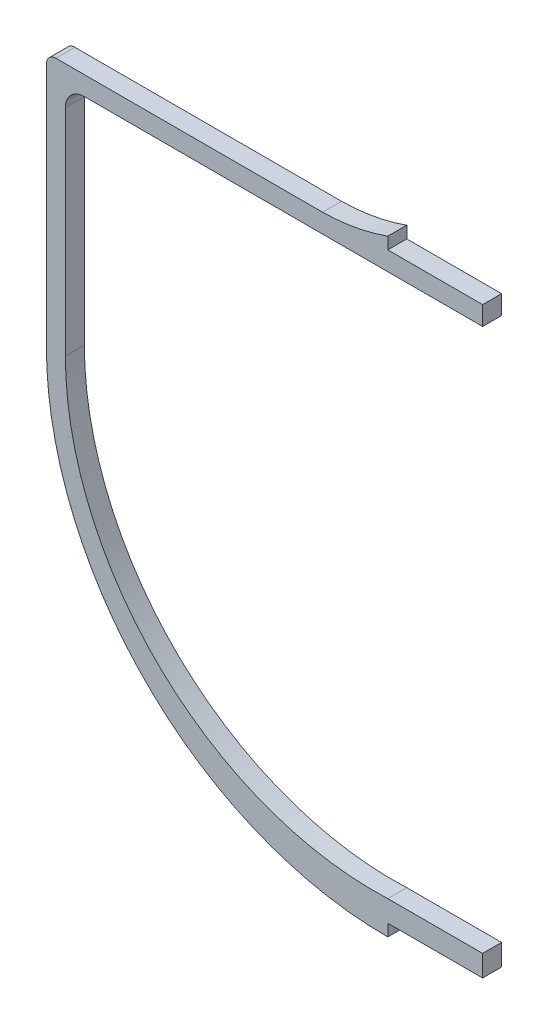
from build123d import *

# Parameters (mm, degrees)
BOSS_EXTRUDE1_DEPTH = 4
FILLET1_R           = 4
FILLET2_R           = 2


with BuildPart() as part:
    # Sketch1 → Boss-Extrude1 (new body)
    with BuildSketch(Plane.XY):
        with BuildLine():
            Line((0, 0), (0, 2.5))
            Line((0, 2.5), (20, 2.5))
            Line((20, 2.5), (20, 7))
            Line((20, 7), (0, 7))
            ThreePointArc((0, 7), (-47.899542657, 25.027060394), (-68, 72.09416895))
            Line((-68, 72.09416895), (-68, 121.5))
            Line((-68, 121.5), (20, 121.5))
            Line((20, 121.5), (20, 125.5))
            Line((20, 125.5), (0, 125.5))
            Line((0, 125.5), (0, 128))
            ThreePointArc((0, 128), (-6.772700236, 126.180912146), (-13.752306798, 125.5))
            Line((-13.752306798, 125.5), (-68, 125.5))
            Line((-68, 125.5), (-72, 125.5))
            Line((-72, 125.5), (-72, 72.09416895))
            ThreePointArc((-72, 72.09416895), (-51.025872308, 21.040838867), (0, 0))
        make_face()
    extrude(amount=BOSS_EXTRUDE1_DEPTH)

    # Fillet1
    fillet1_edges = [part.edges().sort_by_distance(p)[0] for p in [
        (-68, 121.5, 2),
    ]]
    fillet(fillet1_edges, radius=FILLET1_R)

    # Fillet2
    fillet2_edges = [part.edges().sort_by_distance(p)[0] for p in [
        (-72, 125.5, 2),
    ]]
    fillet(fillet2_edges, radius=FILLET2_R)


solid = part.part
